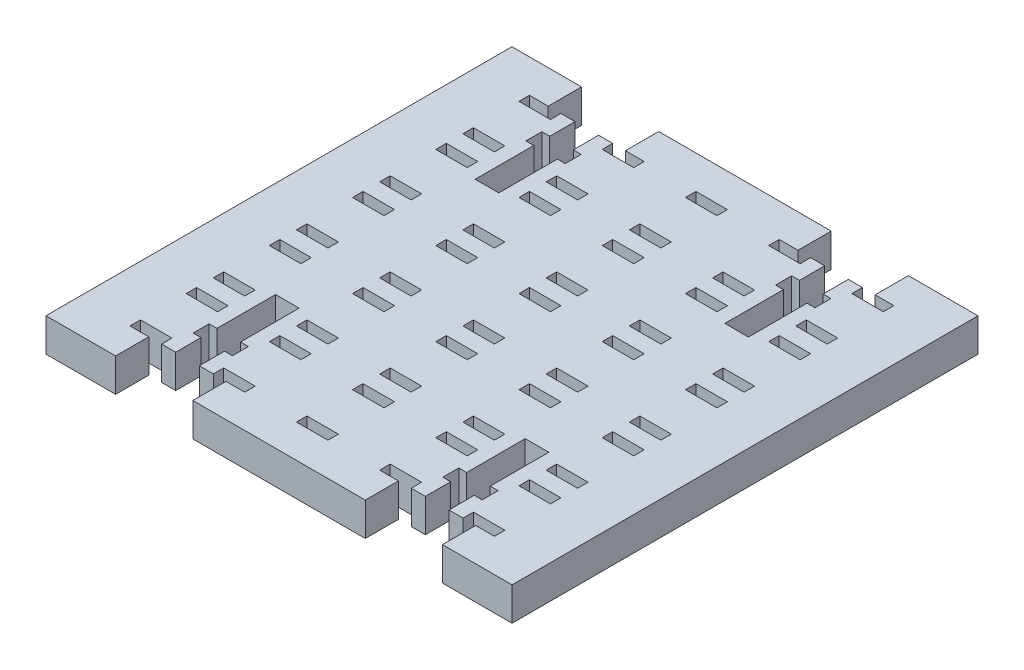
from build123d import *

# Parameters (mm, degrees)
SKETCH1_W            = 168.275
SKETCH1_H            = 168.275
BOSS_EXTRUDE1_DEPTH  = 6.35
SKETCH22_W           = 6
SKETCH22_H           = 2
CUT_EXTRUDE1_DEPTH   = 7.35
LPATTERN1_COUNT      = 5
LPATTERN1_PITCH      = 15.875
LPATTERN1_COUNT_DIR2 = 5
LPATTERN1_PITCH_DIR2 = 15.875
SKETCH28_OUTSIDE_W   = 217.887
SKETCH28_OUTSIDE_H   = 217.887
SKETCH28_OUTSIDE_W_2 = 88.9
SKETCH28_OUTSIDE_H_2 = 88.876510552
CUT_EXTRUDE8_DEPTH   = 7.35
CUT_EXTRUDE9_DEPTH   = 7.35


with BuildPart() as part:
    # Sketch1 → Boss-Extrude1 (new body)
    with BuildSketch(Plane(origin=(0, 0, 0), x_dir=(1, 0, 0), z_dir=(0, 1, 0))):
        with Locations((84.1375, -84.1375)):
            Rectangle(SKETCH1_W, SKETCH1_H)
    extrude(amount=BOSS_EXTRUDE1_DEPTH)

    # Sketch22 → Cut-Extrude1 (cut, through all)
    with BuildSketch(Plane(origin=(0, 6.35, 0), x_dir=(1, 0, 0), z_dir=(0, 1, 0))):
        Polygon((12.7, -8.35), (15.7, -8.35), (15.7, -6.35), (9.7, -6.35), (9.7, -8.35), align=None)
        with Locations((12.7, -18.05)):
            Rectangle(SKETCH22_W, SKETCH22_H)
    cut_extrude1 = extrude(amount=-CUT_EXTRUDE1_DEPTH, mode=Mode.SUBTRACT)

    # LPattern1: Cut-Extrude1 5 × 5
    with Locations(*[(i * LPATTERN1_PITCH, 0, j * LPATTERN1_PITCH_DIR2) for i in range(LPATTERN1_COUNT) for j in range(LPATTERN1_COUNT_DIR2) if (i, j) != (0, 0)]):
        add(cut_extrude1, mode=Mode.SUBTRACT)

    # Sketch28 outside → Cut-Extrude8 (cut, through all)
    with BuildSketch(Plane(origin=(0, 6.35, 0), x_dir=(1, 0, 0), z_dir=(0, 1, 0))):
        with Locations((84.1375, -84.1375)):
            Rectangle(SKETCH28_OUTSIDE_W, SKETCH28_OUTSIDE_H)
        with Locations((44.45, -44.438255276)):
            Rectangle(SKETCH28_OUTSIDE_W_2, SKETCH28_OUTSIDE_H_2, mode=Mode.SUBTRACT)
    extrude(amount=-CUT_EXTRUDE8_DEPTH, mode=Mode.SUBTRACT)

    # Sketch29 → Cut-Extrude9 (cut, through all)
    with BuildSketch(Plane(origin=(0, 6.35, 0), x_dir=(1, 0, 0), z_dir=(0, 1, 0))):
        Polygon((13.275, -6.35), (18.3875, -6.35), (18.3875, -11.176), (16.8875, -11.176), (16.8875, -12.7), (16.8875, -14.224), (18.3875, -14.224), (18.3875, -25.4), (22.8875, -25.4), (22.8875, -14.224), (24.3875, -14.224), (24.3875, -12.7), (24.3875, -11.176), (22.8875, -11.176), (22.8875, -6.35), (28, -6.35), (28, 0), (13.275, 0), align=None)
        Polygon((22.8875, -74.652510552), (24.3875, -74.652510552), (24.3875, -76.176510552), (24.3875, -77.700510552), (22.8875, -77.700510552), (22.8875, -82.526510552), (28, -82.526510552), (28, -88.876510552), (13.275, -88.876510552), (13.275, -82.526510552), (18.3875, -82.526510552), (18.3875, -77.700510552), (16.8875, -77.700510552), (16.8875, -76.176510552), (16.8875, -74.652510552), (18.3875, -74.652510552), (18.3875, -63.476510552), (22.8875, -63.476510552), align=None)
        Polygon((66.0125, -14.224), (64.5125, -14.224), (64.5125, -12.7), (64.5125, -11.176), (66.0125, -11.176), (66.0125, -6.35), (60.9, -6.35), (60.9, 0), (75.625, 0), (75.625, -6.35), (70.5125, -6.35), (70.5125, -11.176), (72.0125, -11.176), (72.0125, -12.7), (72.0125, -14.224), (70.5125, -14.224), (70.5125, -25.4), (66.0125, -25.4), align=None)
        Polygon((75.625, -82.526510552), (70.5125, -82.526510552), (70.5125, -77.700510552), (72.0125, -77.700510552), (72.0125, -76.176510552), (72.0125, -74.652510552), (70.5125, -74.652510552), (70.5125, -63.476510552), (66.0125, -63.476510552), (66.0125, -74.652510552), (64.5125, -74.652510552), (64.5125, -76.176510552), (64.5125, -77.700510552), (66.0125, -77.700510552), (66.0125, -82.526510552), (60.9, -82.526510552), (60.9, -88.876510552), (75.625, -88.876510552), align=None)
    extrude(amount=-CUT_EXTRUDE9_DEPTH, mode=Mode.SUBTRACT)


solid = part.part
